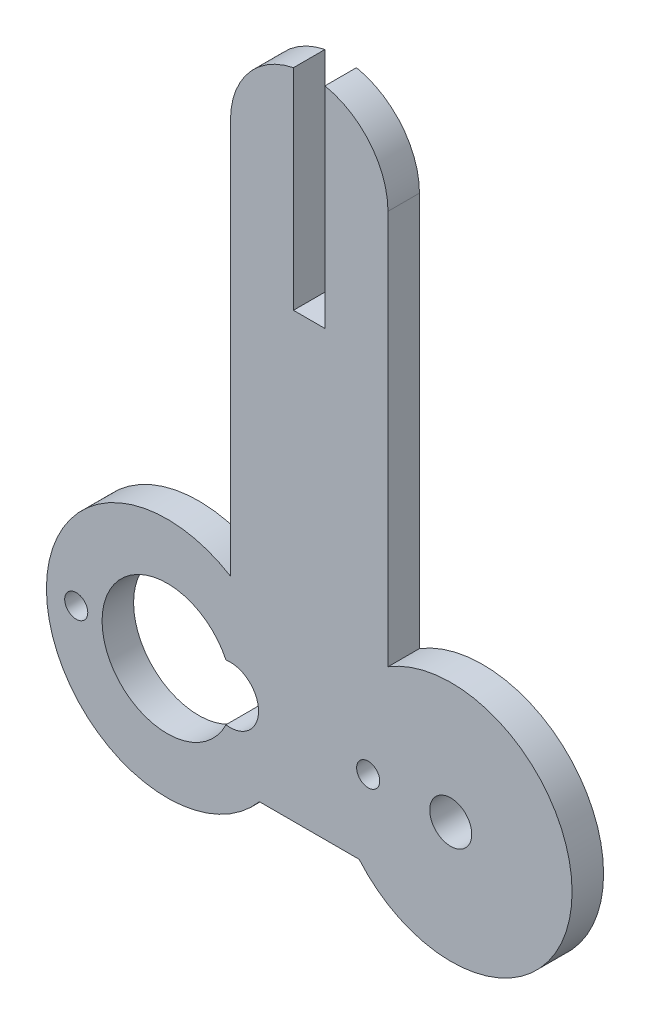
from build123d import *

# Parameters (mm, degrees)
SKETCH3_R           = 1.1
BOSS_EXTRUDE1_DEPTH = 3
SKETCH5_R           = 2
CUT_EXTRUDE1_DEPTH  = 3


with BuildPart() as part:
    # Sketch3 → Boss-Extrude1 (new body)
    with BuildSketch(Plane.XY):
        with BuildLine():
            ThreePointArc((21.010133, 56.127810971), (3.63133679, 44.514906989), (23.766391, 38.905835))
            Line((23.766391, 38.905835), (33.206061, 38.905835))
            Line((33.206061, 38.905835), (33.264681316, 38.905835))
            ThreePointArc((33.264681316, 38.905835), (53.399016999, 44.544189703), (36.010134, 56.154928922))
            Line((36.010134, 56.154928922), (36.010134, 56.158016))
            Line((36.010134, 56.158016), (36.010134, 93.713691502))
            ThreePointArc((36.010134, 93.713691502), (34.319609023, 98.457108027), (30.010134, 101.062160821))
            Line((30.010134, 101.062160821), (30.010134, 101.052906355))
            Line((30.010134, 101.052906355), (30.010134, 81.052906536))
            Line((30.010134, 81.052906536), (27.010134, 81.052906536))
            Line((27.010134, 81.052906536), (27.010134, 101.052906536))
            Line((27.010134, 101.052906536), (27.010134, 101.062160866))
            ThreePointArc((27.010134, 101.062160866), (22.700658897, 98.4571082), (21.010133, 93.713692))
            Line((21.010133, 93.713692), (21.010133, 56.128782))
            Line((21.010133, 56.128782), (21.010133, 56.127810971))
        make_face()
        with Locations((6.326226, 46.332725)):
            Circle(SKETCH3_R, mode=Mode.SUBTRACT)
        with BuildLine():
            ThreePointArc((20.582059495, 43.663146925), (8.78622584, 46.332725409), (20.582059481, 49.002303953))
            ThreePointArc((20.582059481, 49.002303953), (23.686226, 46.332725447), (20.582059495, 43.663146925))
        make_face(mode=Mode.SUBTRACT)
        with Locations((34.126226, 46.332725)):
            Circle(SKETCH3_R, mode=Mode.SUBTRACT)
    extrude(amount=BOSS_EXTRUDE1_DEPTH)

    # Sketch5 → Cut-Extrude1 (cut)
    with BuildSketch(Plane.XY.offset(3)):
        with Locations((41.986225603, 46.332725741)):
            Circle(SKETCH5_R)
    extrude(amount=-CUT_EXTRUDE1_DEPTH, mode=Mode.SUBTRACT)


solid = part.part
